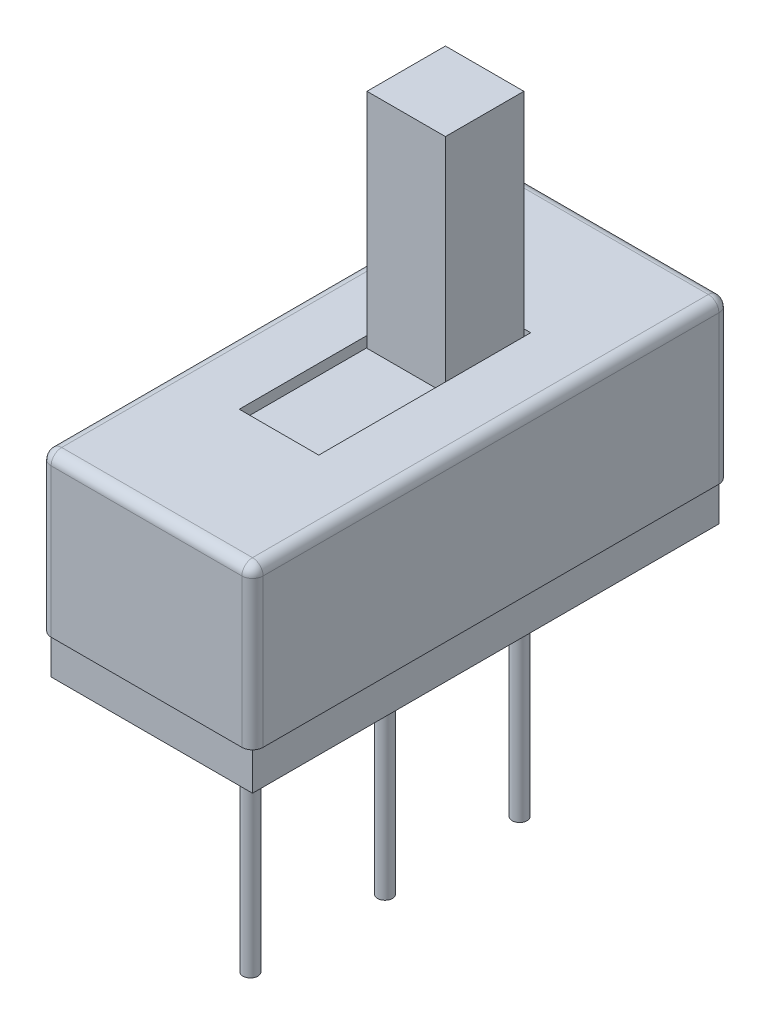
from build123d import *

# Parameters (mm, degrees)
SKETCH1_W               = 3.8
SKETCH1_H               = 8.8
BOSS_EXTRUDE1_DEPTH     = 0.75
BOSS_EXTRUDE2_DEPTH     = 3
SKETCH3_W               = 1.5
SKETCH3_H               = 4
CUT_EXTRUDE1_DEPTH      = 0.2
FILLET1_R               = 0.2
SKETCH4_W               = 2
SKETCH4_H               = 8
CUT_EXTRUDE2_DEPTH      = 2
SKETCH5_R               = 0.14
BOSS_EXTRUDE3_DEPTH     = 4.8
SKETCH6_W               = 1.48
SKETCH6_H               = 1.48
SWITCH_ON_AND_OFF_DEPTH = 6.2
SKETCH7_W               = 2
SKETCH7_H               = 8
BOSS_EXTRUDE5_DEPTH     = 2


with BuildPart() as part:
    # Sketch1 → Boss-Extrude1 (new body)
    with BuildSketch(Plane(origin=(0, 0, 0), x_dir=(1, 0, 0), z_dir=(0, 1, 0))):
        Rectangle(SKETCH1_W, SKETCH1_H)
    extrude(amount=BOSS_EXTRUDE1_DEPTH)

    # Sketch2 → Boss-Extrude2 (add)
    with BuildSketch(Plane(origin=(0, 0.75, 0), x_dir=(1, 0, 0), z_dir=(0, 1, 0))):
        with BuildLine():
            Line((-1.8, 4.5), (1.8, 4.5))
            ThreePointArc((1.8, 4.5), (1.941421356, 4.441421356), (2, 4.3))
            Line((2, 4.3), (2, -4.3))
            ThreePointArc((2, -4.3), (1.941421356, -4.441421356), (1.8, -4.5))
            Line((1.8, -4.5), (-1.8, -4.5))
            ThreePointArc((-1.8, -4.5), (-1.941421356, -4.441421356), (-2, -4.3))
            Line((-2, -4.3), (-2, 4.3))
            ThreePointArc((-2, 4.3), (-1.941421356, 4.441421356), (-1.8, 4.5))
        make_face()
    extrude(amount=BOSS_EXTRUDE2_DEPTH)

    # Sketch3 → Cut-Extrude1 (cut)
    with BuildSketch(Plane(origin=(0, 3.75, 0), x_dir=(1, 0, 0), z_dir=(0, 1, 0))):
        Rectangle(SKETCH3_W, SKETCH3_H)
    extrude(amount=-CUT_EXTRUDE1_DEPTH, mode=Mode.SUBTRACT)

    # Fillet1
    fillet1_edges = [part.edges().sort_by_distance(p)[0] for p in [
        (-1.941421356, 3.75, -4.441421356),
        (-2, 3.75, 0),
        (-1.941421356, 3.75, 4.441421356),
        (0, 3.75, 4.5),
        (1.941421356, 3.75, 4.441421356),
        (2, 3.75, 0),
        (1.941421356, 3.75, -4.441421356),
        (0, 3.75, -4.5),
    ]]
    fillet(fillet1_edges, radius=FILLET1_R)

    # Sketch4 → Cut-Extrude2 (cut)
    with BuildSketch(Plane(origin=(0, 3.55, 0), x_dir=(1, 0, 0), z_dir=(0, 1, 0))):
        Rectangle(SKETCH4_W, SKETCH4_H)
    extrude(amount=-CUT_EXTRUDE2_DEPTH, mode=Mode.SUBTRACT)

    # Sketch5 → Boss-Extrude3 (add)
    with BuildSketch(Plane.XZ):
        with Locations((0, 2.54)):
            Circle(SKETCH5_R)
        Circle(SKETCH5_R)
        with Locations((0, -2.54)):
            Circle(SKETCH5_R)
    extrude(amount=BOSS_EXTRUDE3_DEPTH)


with BuildPart() as body_2:
    # Sketch6 → Switch ON and OFF (new body)
    with BuildSketch(Plane(origin=(0, 1.55, 0), x_dir=(1, 0, 0), z_dir=(0, 1, 0))):
        with Locations((0, 1.14)):
            Rectangle(SKETCH6_W, SKETCH6_H)
    extrude(amount=SWITCH_ON_AND_OFF_DEPTH)

    # Sketch7 → Boss-Extrude5 (add)
    with BuildSketch(Plane(origin=(0, 1.55, 0), x_dir=(1, 0, 0), z_dir=(0, 1, 0))):
        Rectangle(SKETCH7_W, SKETCH7_H)
    extrude(amount=BOSS_EXTRUDE5_DEPTH)


solid = Compound([part.part, body_2.part])
